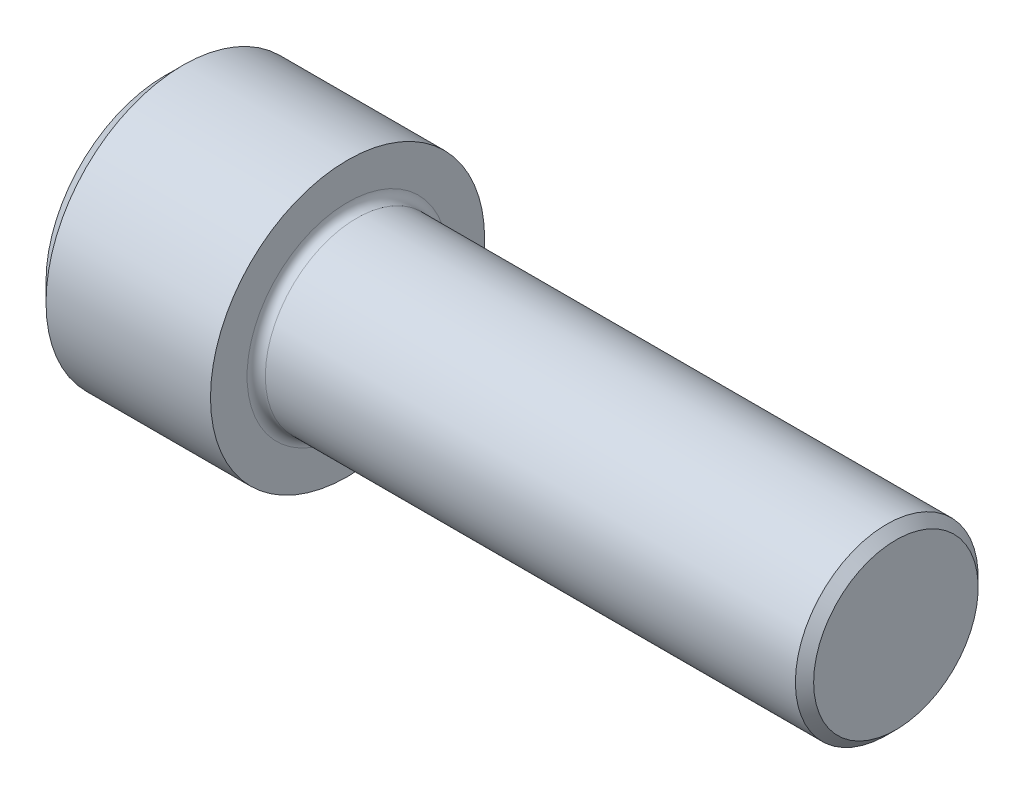
from build123d import *

# Parameters (mm, degrees)
FILLET1_R   = 1.27
HEX_2_DEPTH = 12.573


with BuildPart() as part:
    # BodySke → Base-Revolve (revolve)
    with BuildSketch(Plane.XY, mode=Mode.PRIVATE) as base_revolve_sk:
        Polygon((0, 0), (0, 16.51), (2.54, 19.05), (25.4, 19.05), (25.4, 12.7), (100.33127, 12.7), (101.6, 11.43127), (101.6, 0), align=None)
    revolve(base_revolve_sk.sketch.rotate(Axis((-31.75, 0, 0), (1, 0, 0)), 90), axis=Axis((-31.75, 0, 0), (1, 0, 0)))  # turned: the seam where the file's is

    # Fillet1
    fillet1_edges = [part.edges().sort_by_distance(p)[0] for p in [
        (25.4, 0, -12.7),
    ]]
    fillet(fillet1_edges, radius=FILLET1_R)

    # Sketch2 → Hex-PreBroach (revolve, cut)
    with BuildSketch(Plane.XY, mode=Mode.PRIVATE) as hex_prebroach_sk:
        Polygon((0, 9.525), (12.573, 9.525), (18.072261314, 0), (0, 0), align=None)
    revolve(hex_prebroach_sk.sketch.rotate(Axis((0, 0, 0), (1, 0, 0)), 90), axis=Axis((0, 0, 0), (1, 0, 0)), mode=Mode.SUBTRACT)  # turned: the seam where the file's is

    # Sketch3 → Hex 2 (cut)
    with BuildSketch(Plane(origin=(0, 0, 0), x_dir=(0, 0.5, 0.866025404), z_dir=(-1, 0, 0))):
        Polygon((5.499261314, 9.525), (-5.499261314, 9.525), (-10.998522628, 0), (-5.499261314, -9.525), (5.499261314, -9.525), (10.998522628, 0), align=None)
    extrude(amount=-HEX_2_DEPTH, mode=Mode.SUBTRACT)


solid = part.part
